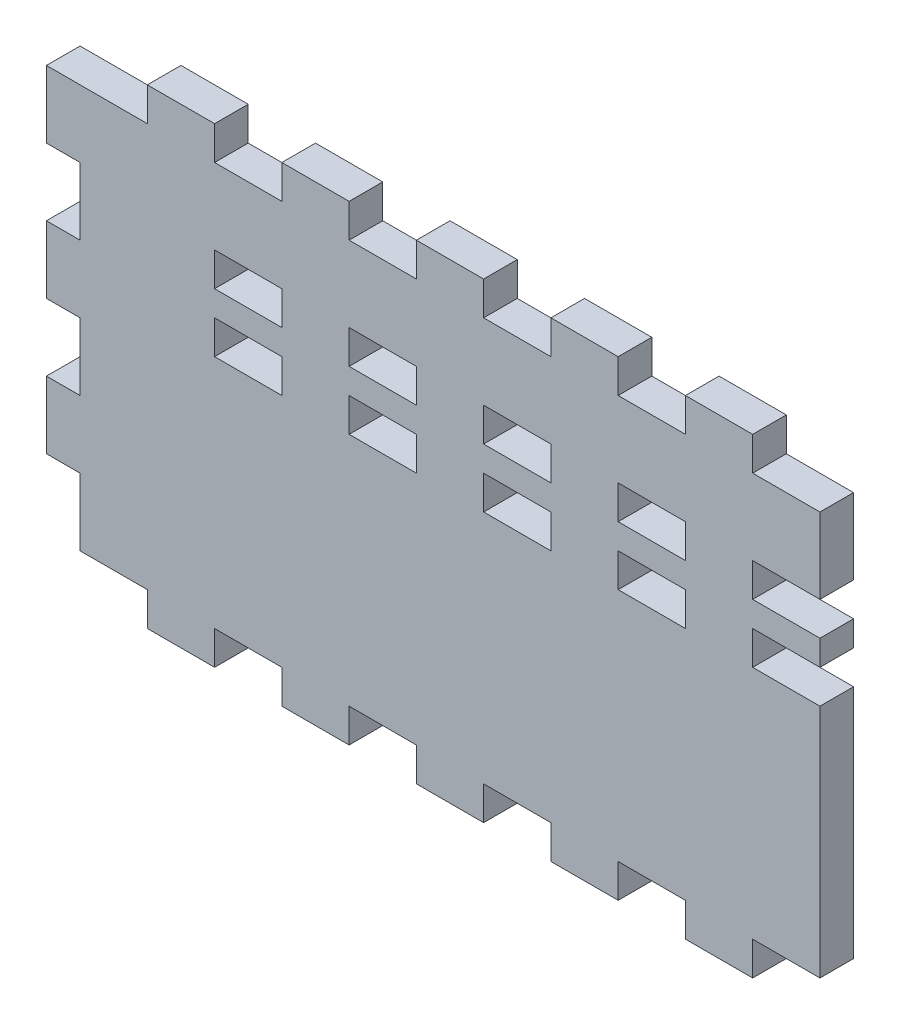
from build123d import *

# Parameters (mm, degrees)
SKETCH1_W               = 279.4
SKETCH1_H               = 152.4
BOSS_EXTRUDE1_DEPTH     = 12.7
SKETCH2_W               = 25.4
SKETCH2_H               = 12.7
BOSS_EXTRUDE2_DEPTH     = 12.7
LPATTERN1_COUNT         = 5
LPATTERN1_PITCH         = 50.8
MIRROR1_COPY_1_SKETCH_W = 25.4
MIRROR1_COPY_1_SKETCH_H = 12.7
MIRROR1_COPY_1_DEPTH    = 12.7
MIRROR1_COPY_2_SKETCH_W = 25.4
MIRROR1_COPY_2_SKETCH_H = 12.7
MIRROR1_COPY_2_DEPTH    = 12.7
MIRROR1_COPY_3_SKETCH_W = 25.4
MIRROR1_COPY_3_SKETCH_H = 12.7
MIRROR1_COPY_3_DEPTH    = 12.7
MIRROR1_COPY_4_SKETCH_W = 25.4
MIRROR1_COPY_4_SKETCH_H = 12.7
MIRROR1_COPY_4_DEPTH    = 12.7
SKETCH3_W               = 12.7
SKETCH3_H               = 25.4
BOSS_EXTRUDE3_DEPTH     = 12.7
LPATTERN2_COUNT         = 3
LPATTERN2_PITCH         = 50.8
SKETCH4_W               = 25.4
SKETCH4_H               = 12.7
CUT_EXTRUDE1_DEPTH      = 13.7
LPATTERN3_COUNT         = 5
LPATTERN3_PITCH         = 50.8
SKETCH5_W               = 25.4
SKETCH5_H               = 12.7
CUT_EXTRUDE2_DEPTH      = 13.7
LPATTERN4_COUNT         = 5
LPATTERN4_PITCH         = 50.8


with BuildPart() as part:
    # Sketch1 → Boss-Extrude1 (new body)
    with BuildSketch(Plane.XY):
        Rectangle(SKETCH1_W, SKETCH1_H)
    extrude(amount=BOSS_EXTRUDE1_DEPTH)

    # Sketch2 → Boss-Extrude2 (add)
    with BuildSketch(Plane.XZ.offset(76.2)):
        with Locations((-101.6, 6.35)):
            Rectangle(SKETCH2_W, SKETCH2_H)
    boss_extrude2 = extrude(amount=BOSS_EXTRUDE2_DEPTH)

    # LPattern1: Boss-Extrude2 ×5
    with Locations(*[(i * LPATTERN1_PITCH, 0, 0) for i in range(1, LPATTERN1_COUNT)]):
        add(boss_extrude2)

    # Mirror1: Boss-Extrude2 across plane
    add(boss_extrude2.mirror(Plane.ZX))

    # Mirror1 copy 1 sketch → Mirror1 copy 1 (add)
    with BuildSketch(Plane(origin=(50.8, 76.2, 0), x_dir=(1, 0, 0), z_dir=(0, 1, 0))):
        with Locations((-101.6, -6.35)):
            Rectangle(MIRROR1_COPY_1_SKETCH_W, MIRROR1_COPY_1_SKETCH_H)
    extrude(amount=MIRROR1_COPY_1_DEPTH)

    # Mirror1 copy 2 sketch → Mirror1 copy 2 (add)
    with BuildSketch(Plane(origin=(101.6, 76.2, 0), x_dir=(1, 0, 0), z_dir=(0, 1, 0))):
        with Locations((-101.6, -6.35)):
            Rectangle(MIRROR1_COPY_2_SKETCH_W, MIRROR1_COPY_2_SKETCH_H)
    extrude(amount=MIRROR1_COPY_2_DEPTH)

    # Mirror1 copy 3 sketch → Mirror1 copy 3 (add)
    with BuildSketch(Plane(origin=(152.4, 76.2, 0), x_dir=(1, 0, 0), z_dir=(0, 1, 0))):
        with Locations((-101.6, -6.35)):
            Rectangle(MIRROR1_COPY_3_SKETCH_W, MIRROR1_COPY_3_SKETCH_H)
    extrude(amount=MIRROR1_COPY_3_DEPTH)

    # Mirror1 copy 4 sketch → Mirror1 copy 4 (add)
    with BuildSketch(Plane(origin=(203.2, 76.2, 0), x_dir=(1, 0, 0), z_dir=(0, 1, 0))):
        with Locations((-101.6, -6.35)):
            Rectangle(MIRROR1_COPY_4_SKETCH_W, MIRROR1_COPY_4_SKETCH_H)
    extrude(amount=MIRROR1_COPY_4_DEPTH)

    # Sketch3 → Boss-Extrude3 (add)
    with BuildSketch(Plane.ZY.offset(139.7)):
        with Locations((6.35, 63.5)):
            Rectangle(SKETCH3_W, SKETCH3_H)
    boss_extrude3 = extrude(amount=BOSS_EXTRUDE3_DEPTH)

    # LPattern2: Boss-Extrude3 ×3
    with Locations(*[(0, -i * LPATTERN2_PITCH, 0) for i in range(1, LPATTERN2_COUNT)]):
        add(boss_extrude3)

    # Sketch4 → Cut-Extrude1 (cut, through all)
    with BuildSketch(Plane(origin=(0, 0, 0), x_dir=(-1, 0, 0), z_dir=(0, 0, -1))):
        with Locations((-127, 19.05)):
            Rectangle(SKETCH4_W, SKETCH4_H)
    cut_extrude1 = extrude(amount=-CUT_EXTRUDE1_DEPTH, mode=Mode.SUBTRACT)

    # LPattern3: Cut-Extrude1 ×5
    with Locations(*[(-i * LPATTERN3_PITCH, 0, 0) for i in range(1, LPATTERN3_COUNT)]):
        add(cut_extrude1, mode=Mode.SUBTRACT)

    # Sketch5 → Cut-Extrude2 (cut, through all)
    with BuildSketch(Plane.XY.offset(12.7)):
        with Locations((-76.2, 41.275)):
            Rectangle(SKETCH5_W, SKETCH5_H)
    cut_extrude2 = extrude(amount=-CUT_EXTRUDE2_DEPTH, mode=Mode.SUBTRACT)

    # LPattern4: Cut-Extrude2 ×5
    with Locations(*[(i * LPATTERN4_PITCH, 0, 0) for i in range(1, LPATTERN4_COUNT)]):
        add(cut_extrude2, mode=Mode.SUBTRACT)


solid = part.part
